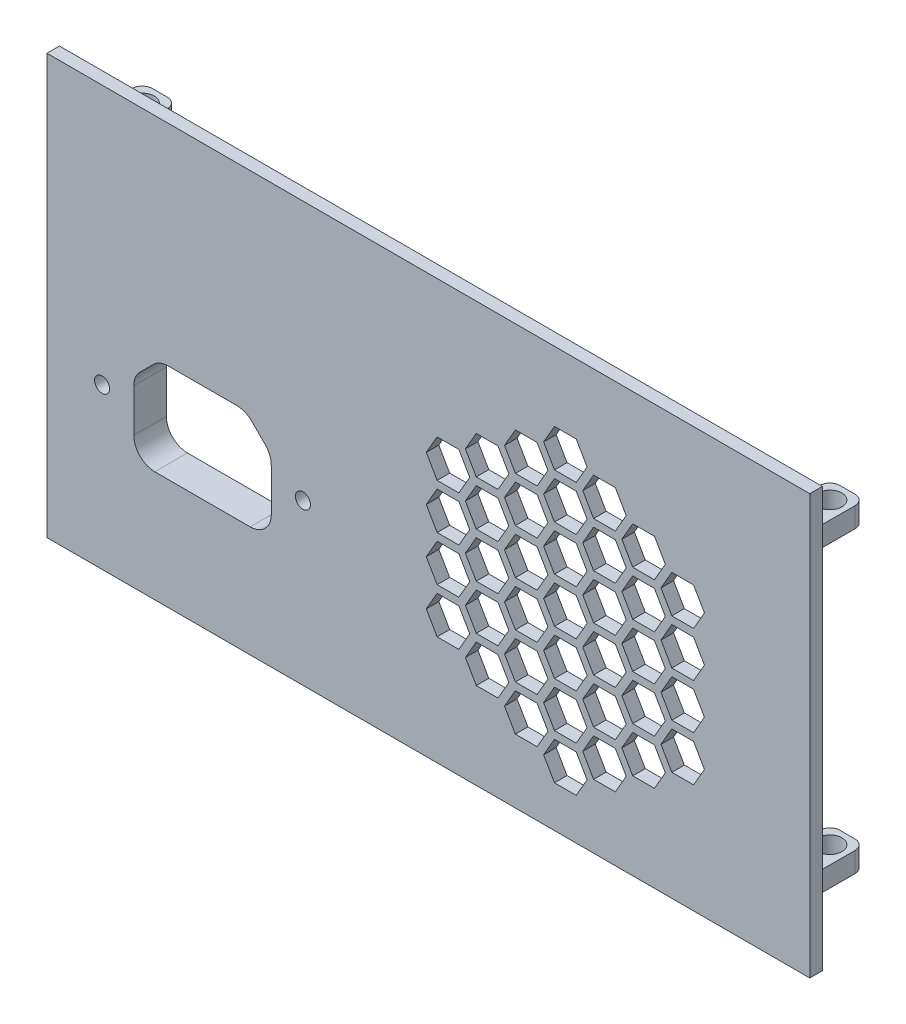
from build123d import *

# Parameters (mm, degrees)
SKETCH1_W           = 152
SKETCH1_H           = 83.58
BOSS_EXTRUDE1_DEPTH = 2.5
SKETCH2_W           = 1.5
SKETCH2_H           = 58.58
SKETCH2_W_2         = 127
SKETCH2_H_2         = 1.5
BOSS_EXTRUDE2_DEPTH = 2.5
SKETCH3_W           = 0.3
SKETCH3_H           = 2.08
SKETCH3_H_2         = 1
SKETCH3_W_2         = 7
SKETCH3_H_3         = 4
BOSS_EXTRUDE3_DEPTH = 12.5
SKETCH4_R           = 2.4
CUT_EXTRUDE1_DEPTH  = 4
FILLET1_R           = 2
FILLET2_R           = 1
SKETCH5_R           = 2.4
CUT_EXTRUDE2_DEPTH  = 4
BOSS_EXTRUDE4_DEPTH = 4
CUT_EXTRUDE3_DEPTH  = 5
SKETCH7_R           = 1.5
CUT_EXTRUDE4_DEPTH  = 5
CUT_EXTRUDE5_DEPTH  = 3


with BuildPart() as part:
    # Sketch1 → Boss-Extrude1 (new body)
    with BuildSketch(Plane.XY.offset(20.837193377)):
        with Locations((109.434575315, 55.017795872)):
            Rectangle(SKETCH1_W, SKETCH1_H)
    extrude(amount=BOSS_EXTRUDE1_DEPTH)

    # Sketch2 → Boss-Extrude2 (add)
    with BuildSketch(Plane(origin=(0, 0, 20.837193377), x_dir=(-1, 0, 0), z_dir=(0, 0, -1))):
        with Locations((-181.884575315, 55.017795872)):
            Rectangle(SKETCH2_W, SKETCH2_H)
        with Locations((-109.434575315, 93.257795872)):
            Rectangle(SKETCH2_W_2, SKETCH2_H_2)
        with Locations((-36.984575315, 55.017795872)):
            Rectangle(SKETCH2_W, SKETCH2_H)
        with Locations((-109.434575315, 16.777795872)):
            Rectangle(SKETCH2_W_2, SKETCH2_H_2)
    extrude(amount=BOSS_EXTRUDE2_DEPTH)

    # Sketch3 → Boss-Extrude3 (add)
    with BuildSketch(Plane(origin=(0, 0, 20.837193377), x_dir=(-1, 0, 0), z_dir=(0, 0, -1))):
        Polygon((-44.434575315, 82.227795872), (-37.734575315, 82.227795872), (-37.734575315, 84.307795872), (-37.434575315, 84.307795872), (-37.434575315, 86.227795872), (-44.434575315, 86.227795872), align=None)
        Polygon((-42.434575315, 22.727795872), (-39.434575315, 22.727795872), (-37.434575315, 22.727795872), (-37.434575315, 25.727795872), (-37.734575315, 25.727795872), (-37.734575315, 26.727795872), (-44.434575315, 26.727795872), (-44.434575315, 22.727795872), align=None)
        Polygon((-181.134575315, 84.307795872), (-181.134575315, 82.227795872), (-174.434575315, 82.227795872), (-174.434575315, 86.227795872), (-181.434575315, 86.227795872), (-181.434575315, 84.307795872), align=None)
        with Locations((-181.284575315, 83.267795872)):
            Rectangle(SKETCH3_W, SKETCH3_H)
        with Locations((-37.584575315, 83.267795872)):
            Rectangle(SKETCH3_W, SKETCH3_H)
        with Locations((-37.584575315, 26.227795872)):
            Rectangle(SKETCH3_W, SKETCH3_H_2)
        with Locations((-177.934575315, 24.727795872)):
            Rectangle(SKETCH3_W_2, SKETCH3_H_3)
    extrude(amount=BOSS_EXTRUDE3_DEPTH)

    # Sketch4 → Cut-Extrude1 (cut)
    with BuildSketch(Plane(origin=(0, 26.727795872, 0), x_dir=(1, 0, 0), z_dir=(0, 1, 0))):
        with Locations(Location((177.934575315, -11.837193377, 0), (0, 0, 270))):
            Circle(SKETCH4_R)
        with Locations(Location((40.934575315, -11.837193377, 0), (0, 0, 270))):
            Circle(SKETCH4_R)
    extrude(amount=-CUT_EXTRUDE1_DEPTH, mode=Mode.SUBTRACT)

    # Fillet1
    fillet1_edges = [part.edges().sort_by_distance(p)[0] for p in [
        (44.434575315, 84.227795872, 8.337193377),
        (37.434575315, 84.227795872, 8.337193377),
        (44.434575315, 24.727795872, 8.337193377),
        (37.434575315, 24.727795872, 8.337193377),
        (181.434575315, 24.727795872, 8.337193377),
        (174.434575315, 24.727795872, 8.337193377),
        (181.434575315, 84.227795872, 8.337193377),
        (174.434575315, 84.227795872, 8.337193377),
    ]]
    fillet(fillet1_edges, radius=FILLET1_R)

    # Fillet2
    fillet2_edges = [part.edges().sort_by_distance(p)[0] for p in [
        (44.434575315, 84.227795872, 20.837193377),
        (41.084575315, 82.227795872, 20.837193377),
        (37.434575315, 85.267795872, 20.837193377),
        (37.434575315, 24.227795872, 20.837193377),
        (41.084575315, 26.727795872, 20.837193377),
        (44.434575315, 24.727795872, 20.837193377),
        (177.784575315, 26.727795872, 20.837193377),
        (181.434575315, 24.227795872, 20.837193377),
        (174.434575315, 24.727795872, 20.837193377),
        (177.784575315, 82.227795872, 20.837193377),
        (181.434575315, 85.267795872, 20.837193377),
        (174.434575315, 84.227795872, 20.837193377),
    ]]
    fillet(fillet2_edges, radius=FILLET2_R)

    # Sketch5 → Cut-Extrude2 (cut)
    with BuildSketch(Plane.XZ.offset(-82.227795872)):
        with Locations(Location((40.934575315, 11.837193377, 0), (0, 0, 90))):
            Circle(SKETCH5_R)
        with Locations(Location((177.934575315, 11.837193377, 0), (0, 0, 90))):
            Circle(SKETCH5_R)
    extrude(amount=-CUT_EXTRUDE2_DEPTH, mode=Mode.SUBTRACT)

    # Sketch6 → Boss-Extrude4 (add)
    with BuildSketch(Plane(origin=(0, 0, 20.837193377), x_dir=(-1, 0, 0), z_dir=(0, 0, -1))):
        with BuildLine():
            Line((-80.134575315, 48.070941622), (-80.134575315, 39.527795872))
            ThreePointArc((-80.134575315, 39.527795872), (-78.318637359, 35.143733828), (-73.934575315, 33.327795872))
            Line((-73.934575315, 33.327795872), (-54.934575315, 33.327795872))
            ThreePointArc((-54.934575315, 33.327795872), (-50.550513272, 35.143733828), (-48.734575315, 39.527795872))
            Line((-48.734575315, 39.527795872), (-48.734575315, 48.070941622))
            ThreePointArc((-48.734575315, 48.070941622), (-49.206522214, 50.443578903), (-50.550513272, 52.455003665))
            Line((-50.550513272, 52.455003665), (-53.207367521, 55.111857915))
            ThreePointArc((-53.207367521, 55.111857915), (-55.218792284, 56.455848973), (-57.591429565, 56.927795872))
            Line((-57.591429565, 56.927795872), (-71.277721066, 56.927795872))
            ThreePointArc((-71.277721066, 56.927795872), (-73.650358346, 56.455848973), (-75.661783109, 55.111857915))
            Line((-75.661783109, 55.111857915), (-78.318637359, 52.455003665))
            ThreePointArc((-78.318637359, 52.455003665), (-79.662628417, 50.443578903), (-80.134575315, 48.070941622))
        make_face()
        with BuildLine():
            ThreePointArc((-78.134575315, 39.527795872), (-76.904423796, 36.557947391), (-73.934575315, 35.327795872))
            Line((-73.934575315, 35.327795872), (-54.934575315, 35.327795872))
            ThreePointArc((-54.934575315, 35.327795872), (-51.964726834, 36.557947391), (-50.734575315, 39.527795872))
            Line((-50.734575315, 39.527795872), (-50.734575315, 48.070941622))
            ThreePointArc((-50.734575315, 48.070941622), (-51.054281279, 49.678212038), (-51.964726834, 51.040790103))
            Line((-51.964726834, 51.040790103), (-54.621581084, 53.697644353))
            ThreePointArc((-54.621581084, 53.697644353), (-55.984159149, 54.608089908), (-57.591429565, 54.927795872))
            Line((-57.591429565, 54.927795872), (-71.277721066, 54.927795872))
            ThreePointArc((-71.277721066, 54.927795872), (-72.884991482, 54.608089908), (-74.247569547, 53.697644353))
            Line((-74.247569547, 53.697644353), (-76.904423796, 51.040790103))
            ThreePointArc((-76.904423796, 51.040790103), (-77.814869352, 49.678212038), (-78.134575315, 48.070941622))
            Line((-78.134575315, 48.070941622), (-78.134575315, 39.527795872))
        make_face(mode=Mode.SUBTRACT)
    extrude(amount=BOSS_EXTRUDE4_DEPTH)

    # Sketch6_3 → Cut-Extrude3 (cut)
    with BuildSketch(Plane(origin=(0, 0, 20.837193377), x_dir=(-1, 0, 0), z_dir=(0, 0, -1))):
        with BuildLine():
            Line((-78.134575315, 48.070941622), (-78.134575315, 39.527795872))
            ThreePointArc((-78.134575315, 39.527795872), (-76.904423796, 36.557947391), (-73.934575315, 35.327795872))
            Line((-73.934575315, 35.327795872), (-54.934575315, 35.327795872))
            ThreePointArc((-54.934575315, 35.327795872), (-51.964726834, 36.557947391), (-50.734575315, 39.527795872))
            Line((-50.734575315, 39.527795872), (-50.734575315, 48.070941622))
            ThreePointArc((-50.734575315, 48.070941622), (-51.054281279, 49.678212038), (-51.964726834, 51.040790103))
            Line((-51.964726834, 51.040790103), (-54.621581084, 53.697644353))
            ThreePointArc((-54.621581084, 53.697644353), (-55.984159149, 54.608089908), (-57.591429565, 54.927795872))
            Line((-57.591429565, 54.927795872), (-71.277721066, 54.927795872))
            ThreePointArc((-71.277721066, 54.927795872), (-72.884991482, 54.608089908), (-74.247569547, 53.697644353))
            Line((-74.247569547, 53.697644353), (-76.904423796, 51.040790103))
            ThreePointArc((-76.904423796, 51.040790103), (-77.814869352, 49.678212038), (-78.134575315, 48.070941622))
        make_face()
        with BuildLine():
            ThreePointArc((-71.277721066, 54.727795872), (-72.808454795, 54.423314002), (-74.10614819, 53.556222996))
            Line((-74.10614819, 53.556222996), (-76.76300244, 50.899368747))
            ThreePointArc((-76.76300244, 50.899368747), (-77.630093445, 49.601675352), (-77.934575315, 48.070941622))
            Line((-77.934575315, 48.070941622), (-77.934575315, 39.527795872))
            ThreePointArc((-77.934575315, 39.527795872), (-76.76300244, 36.699368747), (-73.934575315, 35.527795872))
            Line((-73.934575315, 35.527795872), (-54.934575315, 35.527795872))
            ThreePointArc((-54.934575315, 35.527795872), (-52.10614819, 36.699368747), (-50.934575315, 39.527795872))
            Line((-50.934575315, 39.527795872), (-50.934575315, 48.070941622))
            ThreePointArc((-50.934575315, 48.070941622), (-51.239057185, 49.601675352), (-52.10614819, 50.899368747))
            Line((-52.10614819, 50.899368747), (-54.76300244, 53.556222996))
            ThreePointArc((-54.76300244, 53.556222996), (-56.060695835, 54.423314002), (-57.591429565, 54.727795872))
            Line((-57.591429565, 54.727795872), (-71.277721066, 54.727795872))
        make_face(mode=Mode.SUBTRACT)
        with BuildLine():
            Line((-57.591429565, 54.727795872), (-71.277721066, 54.727795872))
            ThreePointArc((-71.277721066, 54.727795872), (-72.808454795, 54.423314002), (-74.10614819, 53.556222996))
            Line((-74.10614819, 53.556222996), (-76.76300244, 50.899368747))
            ThreePointArc((-76.76300244, 50.899368747), (-77.630093445, 49.601675352), (-77.934575315, 48.070941622))
            Line((-77.934575315, 48.070941622), (-77.934575315, 39.527795872))
            ThreePointArc((-77.934575315, 39.527795872), (-76.76300244, 36.699368747), (-73.934575315, 35.527795872))
            Line((-73.934575315, 35.527795872), (-54.934575315, 35.527795872))
            ThreePointArc((-54.934575315, 35.527795872), (-52.10614819, 36.699368747), (-50.934575315, 39.527795872))
            Line((-50.934575315, 39.527795872), (-50.934575315, 48.070941622))
            ThreePointArc((-50.934575315, 48.070941622), (-51.239057185, 49.601675352), (-52.10614819, 50.899368747))
            Line((-52.10614819, 50.899368747), (-54.76300244, 53.556222996))
            ThreePointArc((-54.76300244, 53.556222996), (-56.060695835, 54.423314002), (-57.591429565, 54.727795872))
        make_face()
    extrude(amount=-CUT_EXTRUDE3_DEPTH, mode=Mode.SUBTRACT)

    # Sketch7 → Cut-Extrude4 (cut)
    with BuildSketch(Plane.XY.offset(23.337193377)):
        with Locations((44.434575315, 45.127795872)):
            Circle(SKETCH7_R)
        with Locations((84.434575315, 45.127795872)):
            Circle(SKETCH7_R)
    extrude(amount=-CUT_EXTRUDE4_DEPTH, mode=Mode.SUBTRACT)

    # Sketch8 → Cut-Extrude5 (cut)
    with BuildSketch(Plane.XY.offset(23.337193377)):
        Polygon((157.950536996, 42.477795872), (155.785473486, 38.727795872), (157.950536996, 34.977795872), (162.280664015, 34.977795872), (164.445727524, 38.727795872), (162.280664015, 42.477795872), align=None)
        Polygon((150.15626563, 37.977795872), (147.99120212, 34.227795872), (150.15626563, 30.477795872), (154.486392649, 30.477795872), (156.651456158, 34.227795872), (154.486392649, 37.977795872), align=None)
        Polygon((142.362036996, 33.477795872), (140.196973486, 29.727795872), (142.362036996, 25.977795872), (146.692164015, 25.977795872), (148.857227524, 29.727795872), (146.692164015, 33.477795872), align=None)
        Polygon((134.56776563, 28.977795872), (132.40270212, 25.227795872), (134.56776563, 21.477795872), (138.897892649, 21.477795872), (141.062956158, 25.227795872), (138.897892649, 28.977795872), align=None)
        Polygon((126.773536996, 33.477795872), (124.608473486, 29.727795872), (126.773536996, 25.977795872), (131.103664015, 25.977795872), (133.268727524, 29.727795872), (131.103664015, 33.477795872), align=None)
        Polygon((118.97926563, 37.977795872), (116.81420212, 34.227795872), (118.97926563, 30.477795872), (123.309392649, 30.477795872), (125.474456158, 34.227795872), (123.309392649, 37.977795872), align=None)
        Polygon((111.185036996, 42.477795872), (109.019973486, 38.727795872), (111.185036996, 34.977795872), (115.515164015, 34.977795872), (117.680227524, 38.727795872), (115.515164015, 42.477795872), align=None)
        Polygon((111.185036996, 51.477795872), (109.019973486, 47.727795872), (111.185036996, 43.977795872), (115.515164015, 43.977795872), (117.680227524, 47.727795872), (115.515164015, 51.477795872), align=None)
        Polygon((111.185036996, 60.477795872), (109.019973486, 56.727795872), (111.185036996, 52.977795872), (115.515164015, 52.977795872), (117.680227524, 56.727795872), (115.515164015, 60.477795872), align=None)
        Polygon((111.185036996, 69.477795872), (109.019973486, 65.727795872), (111.185036996, 61.977795872), (115.515164015, 61.977795872), (117.680227524, 65.727795872), (115.515164015, 69.477795872), align=None)
        Polygon((118.97926563, 73.977795872), (116.81420212, 70.227795872), (118.97926563, 66.477795872), (123.309392649, 66.477795872), (125.474456158, 70.227795872), (123.309392649, 73.977795872), align=None)
        Polygon((126.773536996, 78.477795872), (124.608473486, 74.727795872), (126.773536996, 70.977795872), (131.103664015, 70.977795872), (133.268727524, 74.727795872), (131.103664015, 78.477795872), align=None)
        Polygon((134.56776563, 82.977795872), (132.40270212, 79.227795872), (134.56776563, 75.477795872), (138.897892649, 75.477795872), (141.062956158, 79.227795872), (138.897892649, 82.977795872), align=None)
        Polygon((142.362036996, 78.477795872), (140.196973486, 74.727795872), (142.362036996, 70.977795872), (146.692164015, 70.977795872), (148.857227524, 74.727795872), (146.692164015, 78.477795872), align=None)
        Polygon((150.15626563, 73.977795872), (147.99120212, 70.227795872), (150.15626563, 66.477795872), (154.486392649, 66.477795872), (156.651456158, 70.227795872), (154.486392649, 73.977795872), align=None)
        Polygon((157.950536996, 69.477795872), (155.785473486, 65.727795872), (157.950536996, 61.977795872), (162.280664015, 61.977795872), (164.445727524, 65.727795872), (162.280664015, 69.477795872), align=None)
        Polygon((157.950536996, 60.477795872), (155.785473486, 56.727795872), (157.950536996, 52.977795872), (162.280664015, 52.977795872), (164.445727524, 56.727795872), (162.280664015, 60.477795872), align=None)
        Polygon((157.950536996, 51.477795872), (155.785473486, 47.727795872), (157.950536996, 43.977795872), (162.280664015, 43.977795872), (164.445727524, 47.727795872), (162.280664015, 51.477795872), align=None)
        Polygon((150.15626563, 46.977795872), (147.99120212, 43.227795872), (150.15626563, 39.477795872), (154.486392649, 39.477795872), (156.651456158, 43.227795872), (154.486392649, 46.977795872), align=None)
        Polygon((150.15626563, 55.977795872), (147.99120212, 52.227795872), (150.15626563, 48.477795872), (154.486392649, 48.477795872), (156.651456158, 52.227795872), (154.486392649, 55.977795872), align=None)
        Polygon((150.15626563, 64.977795872), (147.99120212, 61.227795872), (150.15626563, 57.477795872), (154.486392649, 57.477795872), (156.651456158, 61.227795872), (154.486392649, 64.977795872), align=None)
        Polygon((142.362036996, 69.477795872), (140.196973486, 65.727795872), (142.362036996, 61.977795872), (146.692164015, 61.977795872), (148.857227524, 65.727795872), (146.692164015, 69.477795872), align=None)
        Polygon((134.56776563, 73.977795872), (132.40270212, 70.227795872), (134.56776563, 66.477795872), (138.897892649, 66.477795872), (141.062956158, 70.227795872), (138.897892649, 73.977795872), align=None)
        Polygon((134.56776563, 64.977795872), (132.40270212, 61.227795872), (134.56776563, 57.477795872), (138.897892649, 57.477795872), (141.062956158, 61.227795872), (138.897892649, 64.977795872), align=None)
        Polygon((142.362036996, 60.477795872), (140.196973486, 56.727795872), (142.362036996, 52.977795872), (146.692164015, 52.977795872), (148.857227524, 56.727795872), (146.692164015, 60.477795872), align=None)
        Polygon((142.362036996, 51.477795872), (140.196973486, 47.727795872), (142.362036996, 43.977795872), (146.692164015, 43.977795872), (148.857227524, 47.727795872), (146.692164015, 51.477795872), align=None)
        Polygon((142.362036996, 42.477795872), (140.196973486, 38.727795872), (142.362036996, 34.977795872), (146.692164015, 34.977795872), (148.857227524, 38.727795872), (146.692164015, 42.477795872), align=None)
        Polygon((134.56776563, 37.977795872), (132.40270212, 34.227795872), (134.56776563, 30.477795872), (138.897892649, 30.477795872), (141.062956158, 34.227795872), (138.897892649, 37.977795872), align=None)
        Polygon((134.56776563, 46.977795872), (132.40270212, 43.227795872), (134.56776563, 39.477795872), (138.897892649, 39.477795872), (141.062956158, 43.227795872), (138.897892649, 46.977795872), align=None)
        Polygon((134.56776563, 55.977795872), (132.40270212, 52.227795872), (134.56776563, 48.477795872), (138.897892649, 48.477795872), (141.062956158, 52.227795872), (138.897892649, 55.977795872), align=None)
        Polygon((126.773536996, 51.477795872), (124.608473486, 47.727795872), (126.773536996, 43.977795872), (131.103664015, 43.977795872), (133.268727524, 47.727795872), (131.103664015, 51.477795872), align=None)
        Polygon((126.773536996, 42.477795872), (124.608473486, 38.727795872), (126.773536996, 34.977795872), (131.103664015, 34.977795872), (133.268727524, 38.727795872), (131.103664015, 42.477795872), align=None)
        Polygon((118.97926563, 46.977795872), (116.81420212, 43.227795872), (118.97926563, 39.477795872), (123.309392649, 39.477795872), (125.474456158, 43.227795872), (123.309392649, 46.977795872), align=None)
        Polygon((118.97926563, 55.977795872), (116.81420212, 52.227795872), (118.97926563, 48.477795872), (123.309392649, 48.477795872), (125.474456158, 52.227795872), (123.309392649, 55.977795872), align=None)
        Polygon((118.97926563, 64.977795872), (116.81420212, 61.227795872), (118.97926563, 57.477795872), (123.309392649, 57.477795872), (125.474456158, 61.227795872), (123.309392649, 64.977795872), align=None)
        Polygon((126.773536996, 69.477795872), (124.608473486, 65.727795872), (126.773536996, 61.977795872), (131.103664015, 61.977795872), (133.268727524, 65.727795872), (131.103664015, 69.477795872), align=None)
        Polygon((126.773536996, 60.477795872), (124.608473486, 56.727795872), (126.773536996, 52.977795872), (131.103664015, 52.977795872), (133.268727524, 56.727795872), (131.103664015, 60.477795872), align=None)
    extrude(amount=-CUT_EXTRUDE5_DEPTH, mode=Mode.SUBTRACT)


solid = part.part
